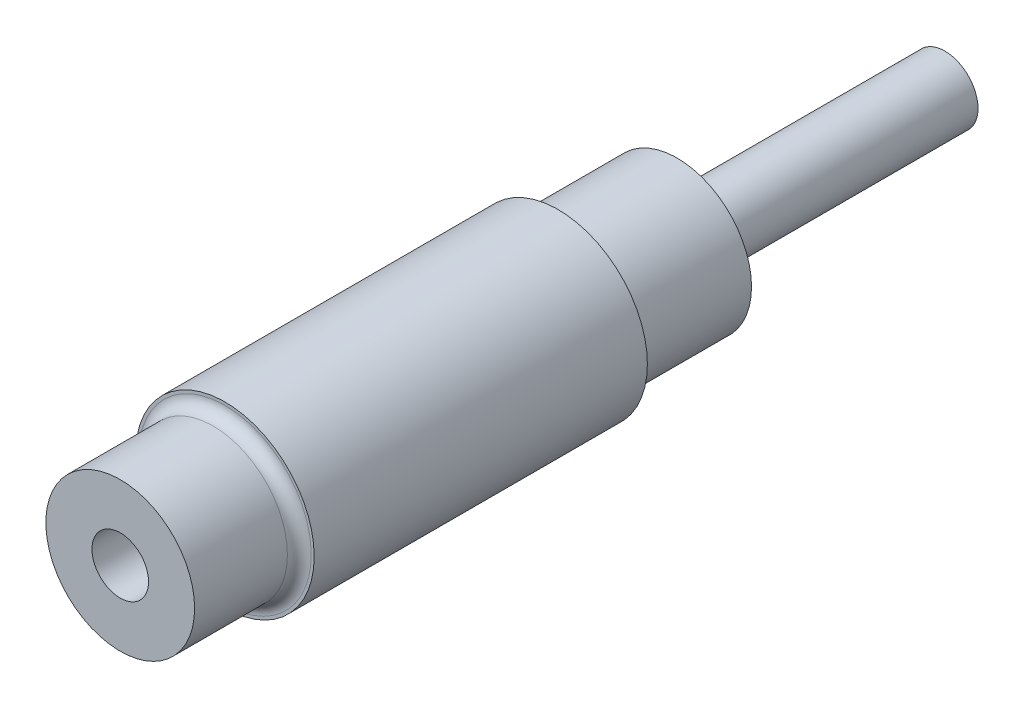
from build123d import *

# Parameters (mm, degrees)
SKETCH1_R           = 12.5
BOSS_EXTRUDE1_DEPTH = 93.6
SKETCH2_R           = 15
BOSS_EXTRUDE2_DEPTH = 56
SKETCH3_R           = 5.565
BOSS_EXTRUDE3_DEPTH = 45
SKETCH4_R           = 4.755
CUT_EXTRUDE1_DEPTH  = 60
FILLET2_R           = 2
FILLET3_R           = 1.5
FILLET4_R           = 2


with BuildPart() as part:
    # Sketch1 → Boss-Extrude1 (new body)
    with BuildSketch(Plane.XY):
        Circle(SKETCH1_R)
    extrude(amount=BOSS_EXTRUDE1_DEPTH)

    # Sketch2 → Boss-Extrude2 (add)
    with BuildSketch(Plane.XY.offset(76)):
        Circle(SKETCH2_R)
    extrude(amount=-BOSS_EXTRUDE2_DEPTH)

    # Sketch3 → Boss-Extrude3 (add)
    with BuildSketch(Plane(origin=(0, 0, 0), x_dir=(-1, 0, 0), z_dir=(0, 0, -1))):
        Circle(SKETCH3_R)
    extrude(amount=BOSS_EXTRUDE3_DEPTH)

    # Sketch4 → Cut-Extrude1 (cut)
    with BuildSketch(Plane.XY.offset(93.6)):
        Circle(SKETCH4_R)
    extrude(amount=-CUT_EXTRUDE1_DEPTH, mode=Mode.SUBTRACT)

    # Fillet2
    fillet2_edges = [part.edges().sort_by_distance(p)[0] for p in [
        (-12.5, 0, 76),
    ]]
    fillet(fillet2_edges, radius=FILLET2_R)

    # Fillet3
    fillet3_edges = [part.edges().sort_by_distance(p)[0] for p in [
        (-12.5, 0, 20),
    ]]
    fillet(fillet3_edges, radius=FILLET3_R)

    # Fillet4
    fillet4_edges = [part.edges().sort_by_distance(p)[0] for p in [
        (5.565, 0, 0),
    ]]
    fillet(fillet4_edges, radius=FILLET4_R)


solid = part.part
